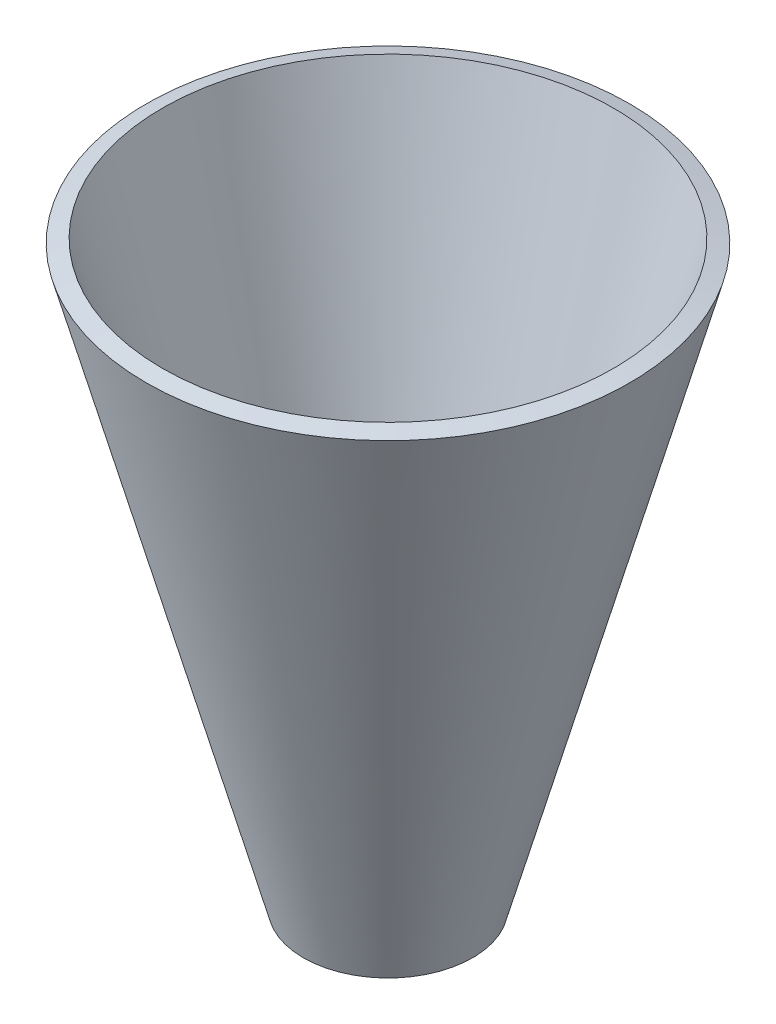
from build123d import *


with BuildPart() as part:
    # Skizze1 → Rotation-Dünn1 (revolve)
    with BuildSketch(Plane.XY):
        Polygon((8.162599391, -32.865051311), (26.872291523, 35.819213227), (28.801978687, 35.293563677), (10.092286555, -33.390700861), align=None)
    revolve(axis=Axis((0, 35.819213227, 0), (0, -1, 0)))


solid = part.part
